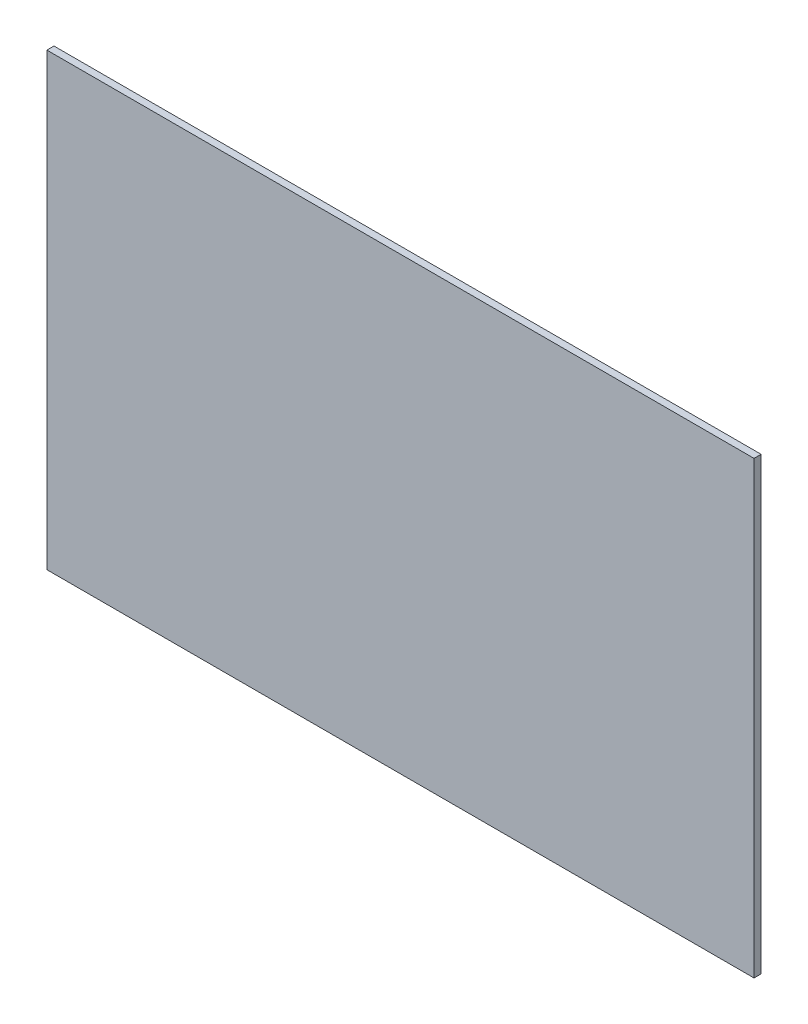
from build123d import *

# Parameters (mm, degrees)
SKETCH1_W           = 279.4
SKETCH1_H           = 177.8
BOSS_EXTRUDE1_DEPTH = 2.794


with BuildPart() as part:
    # Sketch1 → Boss-Extrude1 (new body)
    with BuildSketch(Plane.XY):
        Rectangle(SKETCH1_W, SKETCH1_H)
    extrude(amount=BOSS_EXTRUDE1_DEPTH)


solid = part.part
